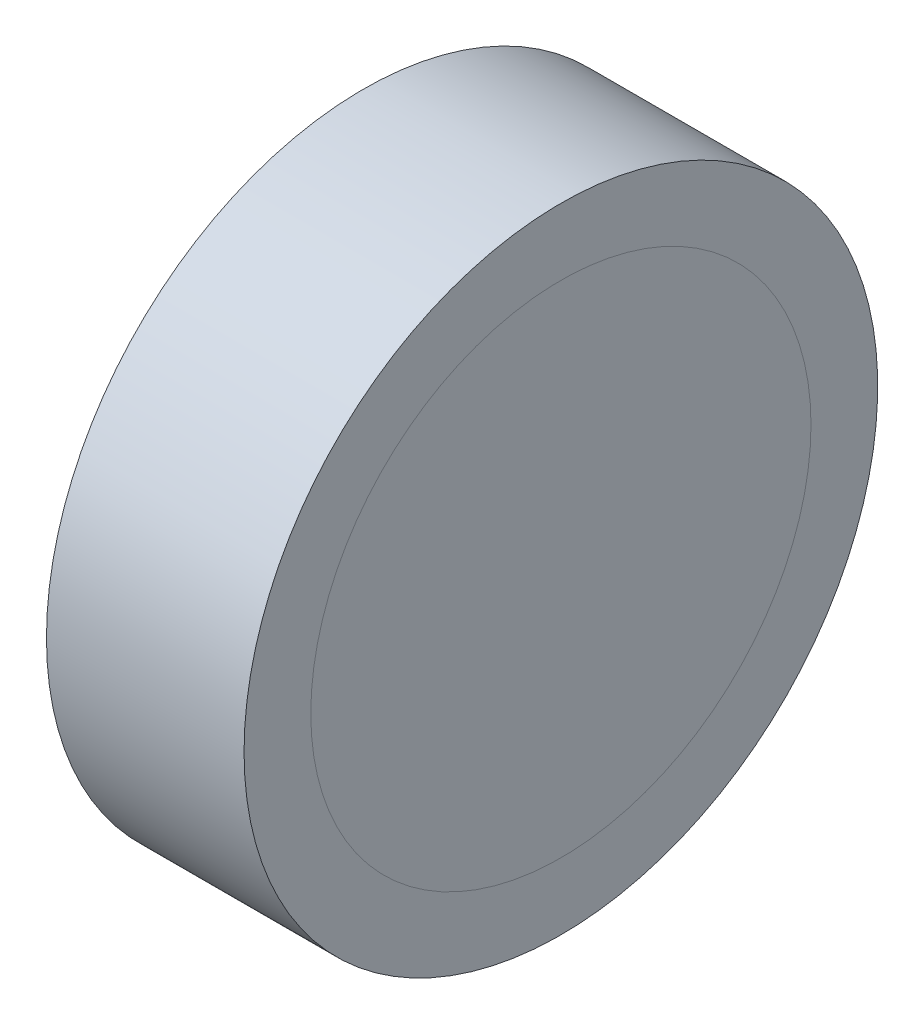
from build123d import *


with BuildPart() as part:
    # Sketch 1 → Revolve 1 (revolve)
    with BuildSketch(Plane.XY, mode=Mode.PRIVATE) as revolve_1_sk:
        Polygon((302.404713074, 75.574237467), (294.484713074, 75.574237467), (294.484713074, 72.899237467), (295.484713074, 72.899237467), (295.484713074, 70.424237467), (301.404713074, 70.424237467), (301.404713074, 72.899237467), (302.404713074, 72.899237467), align=None)
    revolve(revolve_1_sk.sketch.rotate(Axis((286.622526245, 62.874237467, 0), (1, 0, 0)), 90), axis=Axis((286.622526245, 62.874237467, 0), (1, 0, 0)))  # turned: the seam where the file's is


with BuildPart() as body_2:
    # Sketch 1_4 one side → Revolve 2 (revolve)
    with BuildSketch(Plane.XY, mode=Mode.PRIVATE) as revolve_2_sk:
        Polygon((295.484713074, 70.424237467), (295.484713074, 72.899237467), (294.484713074, 72.899237467), (294.484713074, 62.874237467), (295.484713074, 62.874237467), align=None)
    revolve(revolve_2_sk.sketch.rotate(Axis((286.622526245, 62.874237467, 0), (1, 0, 0)), 90), axis=Axis((286.622526245, 62.874237467, 0), (1, 0, 0)))  # turned: the seam where the file's is


with BuildPart() as body_3:
    # Sketch 1_5 one side → Revolve 3 (revolve)
    with BuildSketch(Plane.XY, mode=Mode.PRIVATE) as revolve_3_sk:
        Polygon((301.404713074, 62.874237467), (302.404713074, 62.874237467), (302.404713074, 72.899237467), (301.404713074, 72.899237467), (301.404713074, 70.424237467), align=None)
    revolve(revolve_3_sk.sketch.rotate(Axis((286.622526245, 62.874237467, 0), (1, 0, 0)), 90), axis=Axis((286.622526245, 62.874237467, 0), (1, 0, 0)))  # turned: the seam where the file's is


solid = Compound([part.part, body_2.part, body_3.part])
